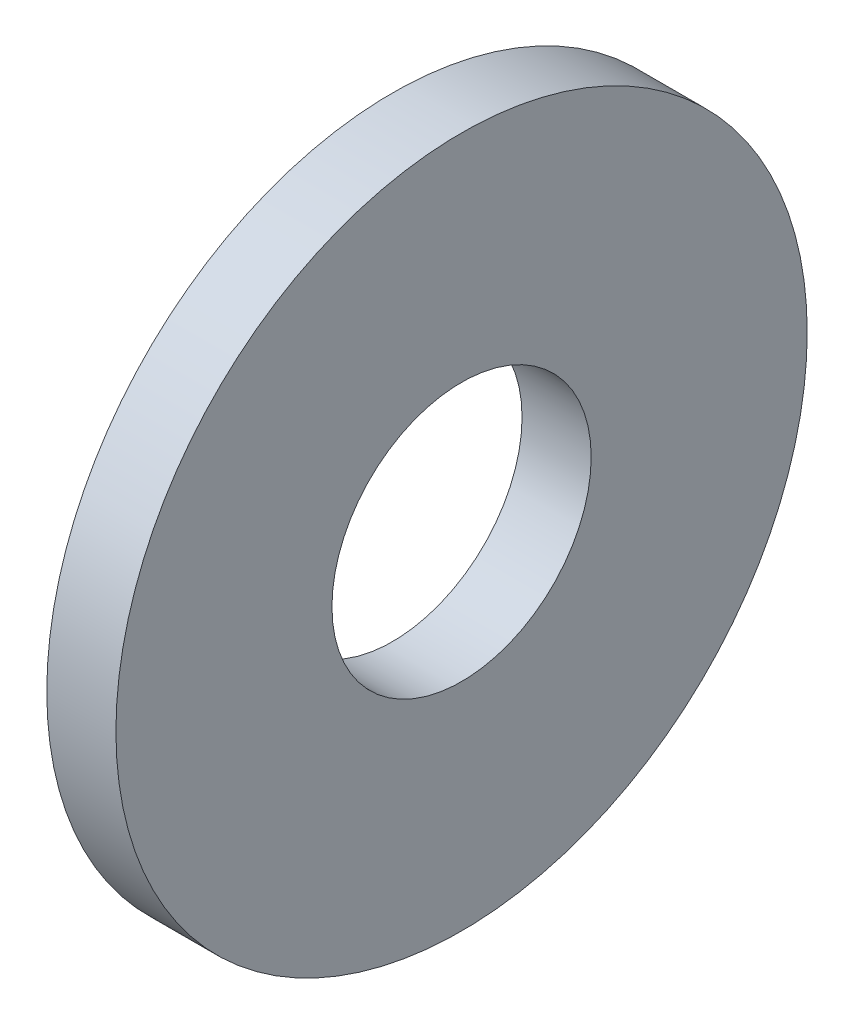
from build123d import *

# Parameters (mm, degrees)
SKETCH1_R          = 3
SKETCH1_R_2        = 1.125
BASE_EXTRUDE_DEPTH = 0.6


with BuildPart() as part:
    # Sketch1 → Base-Extrude (new body)
    with BuildSketch(Plane(origin=(0, 0, 0), x_dir=(0, 0, -1), z_dir=(1, 0, 0))):
        Circle(SKETCH1_R)
        Circle(SKETCH1_R_2, mode=Mode.SUBTRACT)
    extrude(amount=BASE_EXTRUDE_DEPTH)


solid = part.part
